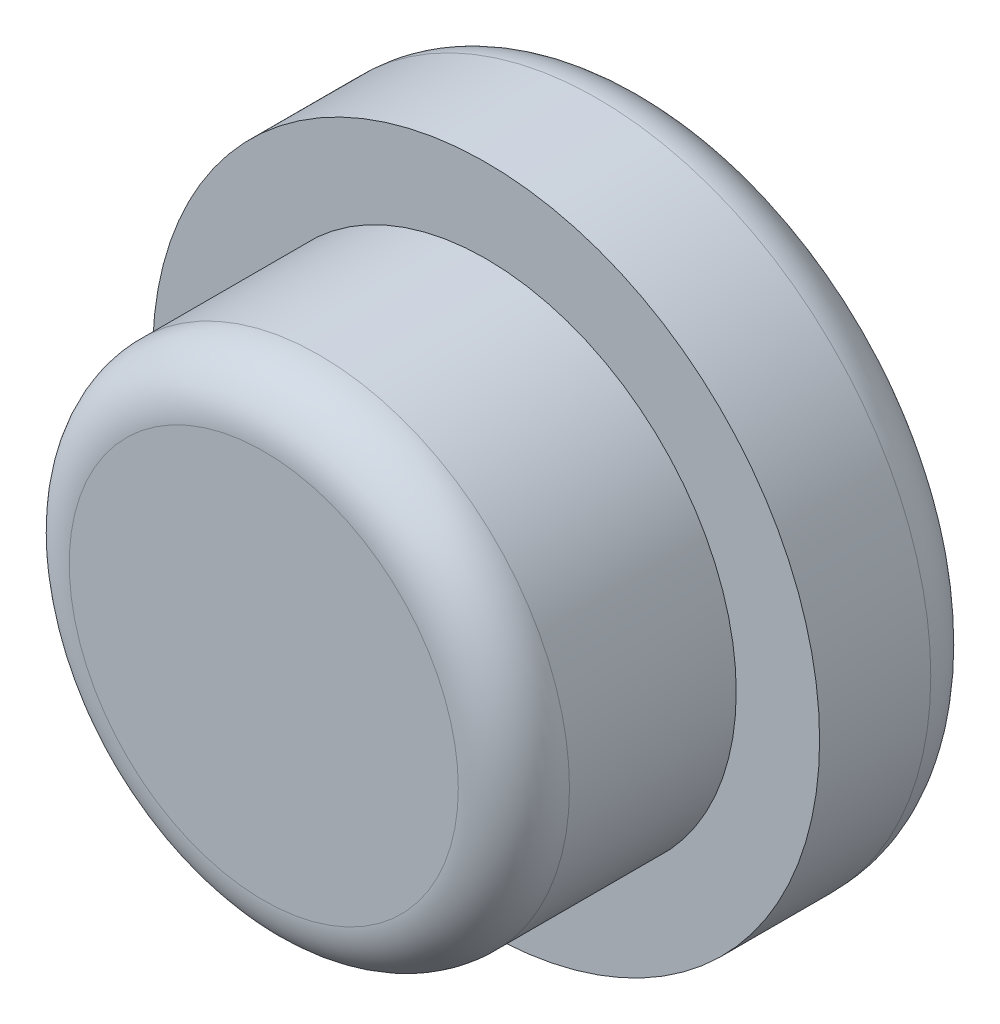
from build123d import *

# Parameters (mm, degrees)
SKETCH_1_R          = 3
EXTRUDE_1_DEPTH     = 1.5
SKETCH_2_R          = 2.25
EXTRUDE_2_DEPTH     = 2
SKETCH_3_R          = 1.5
CUT_EXTRUDE_1_DEPTH = 0.5
FILLET_1_R          = 0.25
FILLET_2_R          = 0.5
FILLET_3_R          = 0.5


with BuildPart() as part:
    # Эскиз1 → Бобышка-Вытянуть1 (new body)
    with BuildSketch(Plane.XY):
        Circle(SKETCH_1_R)
    extrude(amount=EXTRUDE_1_DEPTH)

    # Эскиз2 → Бобышка-Вытянуть2 (add)
    with BuildSketch(Plane.XY.offset(1.5)):
        Circle(SKETCH_2_R)
    extrude(amount=EXTRUDE_2_DEPTH)

    # Эскиз3 → Вырез-Вытянуть1 (cut)
    with BuildSketch(Plane(origin=(0, 0, 0), x_dir=(-1, 0, 0), z_dir=(0, 0, -1))):
        Circle(SKETCH_3_R)
    extrude(amount=-CUT_EXTRUDE_1_DEPTH, mode=Mode.SUBTRACT)

    # Скругление1
    fillet_1_edges = [part.edges().sort_by_distance(p)[0] for p in [
        (1.5, 0, 0.5),
    ]]
    fillet(fillet_1_edges, radius=FILLET_1_R)

    # Скругление2
    fillet_2_edges = [part.edges().sort_by_distance(p)[0] for p in [
        (-2.25, 0, 3.5),
    ]]
    fillet(fillet_2_edges, radius=FILLET_2_R)

    # Скругление3
    fillet_3_edges = [part.edges().sort_by_distance(p)[0] for p in [
        (-3, 0, 0),
    ]]
    fillet(fillet_3_edges, radius=FILLET_3_R)


solid = part.part
